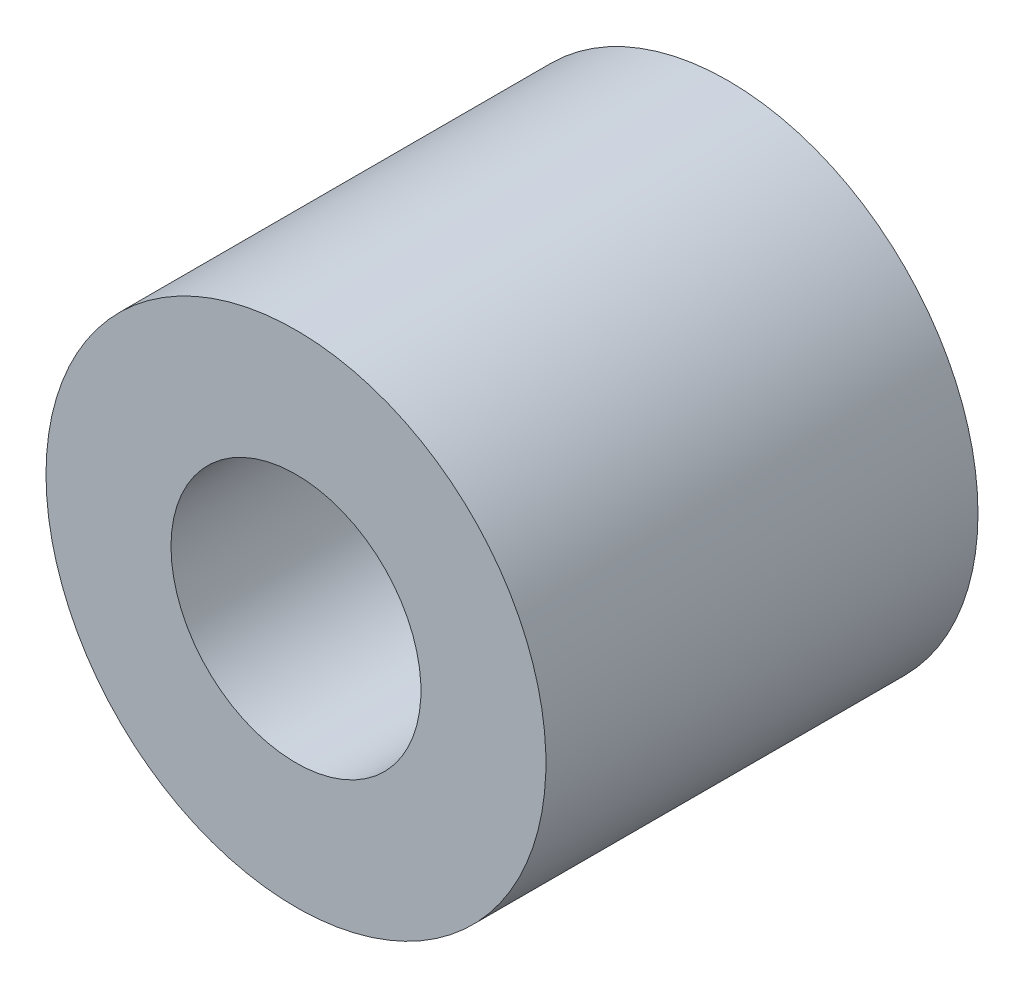
from build123d import *

# Parameters (mm, degrees)
ESQUISSE1_R        = 3.5
ESQUISSE1_R_2      = 1.75
BOSS_EXTRU_1_DEPTH = 6.05


with BuildPart() as part:
    # Esquisse1 → Boss.-Extru.1 (new body)
    with BuildSketch(Plane.XY):
        Circle(ESQUISSE1_R)
        Circle(ESQUISSE1_R_2, mode=Mode.SUBTRACT)
    extrude(amount=BOSS_EXTRU_1_DEPTH)


solid = part.part
